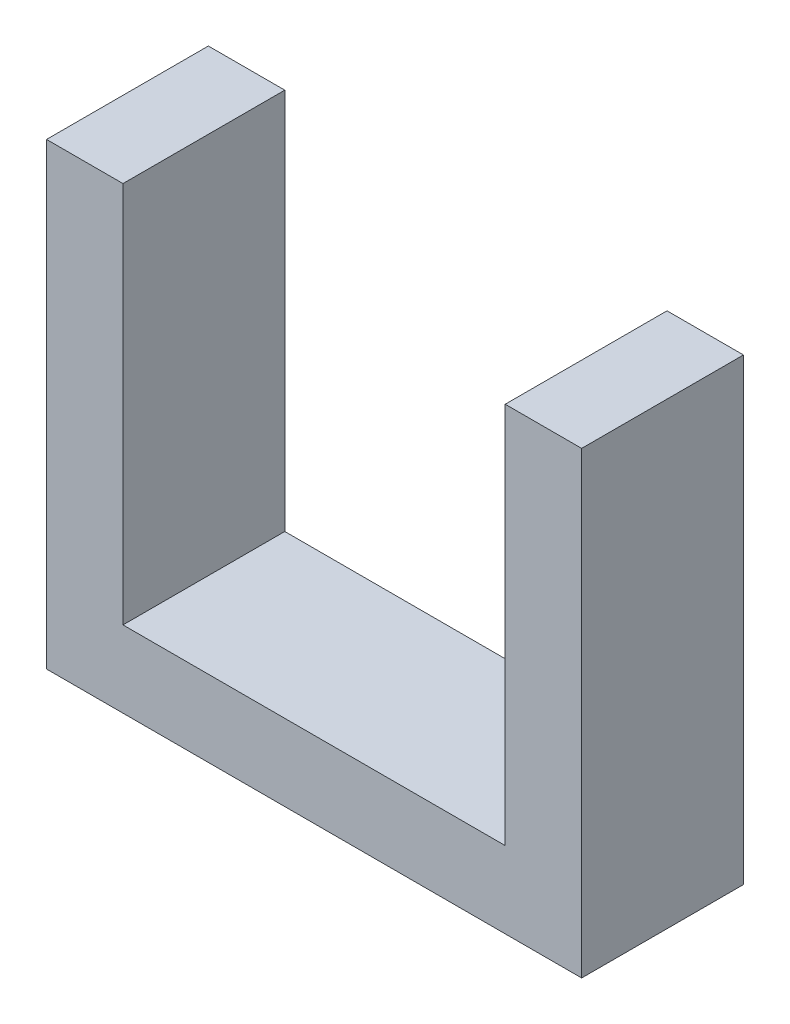
from build123d import *

# Parameters (mm, degrees)
BOSS_EXTRUDE1_DEPTH = 6.35


with BuildPart() as part:
    # Sketch1 → Boss-Extrude1 (new body)
    with BuildSketch(Plane.XY):
        Polygon((-18.28235915, 18.460343312), (-18.28235915, 3.460343312), (-3.28235915, 3.460343312), (-3.28235915, 18.460343312), (-0.28235915, 18.460343312), (-0.28235915, 0.460343312), (-21.28235915, 0.460343312), (-21.28235915, 18.460343312), align=None)
    extrude(amount=BOSS_EXTRUDE1_DEPTH)


solid = part.part
